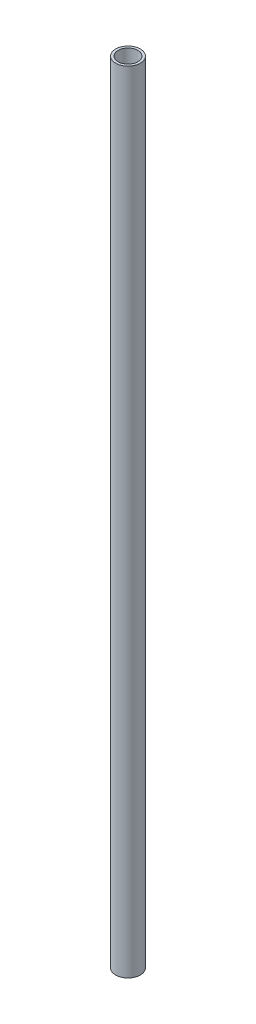
from build123d import *

# Parameters (mm, degrees)
SKETCH1_R           = 4.7625
SKETCH1_R_2         = 3.81
BOSS_EXTRUDE1_DEPTH = 304.8


with BuildPart() as part:
    # Sketch1 → Boss-Extrude1 (new body)
    with BuildSketch(Plane(origin=(0, 0, 0), x_dir=(1, 0, 0), z_dir=(0, 1, 0))):
        Circle(SKETCH1_R)
        Circle(SKETCH1_R_2, mode=Mode.SUBTRACT)
    extrude(amount=BOSS_EXTRUDE1_DEPTH)


solid = part.part
